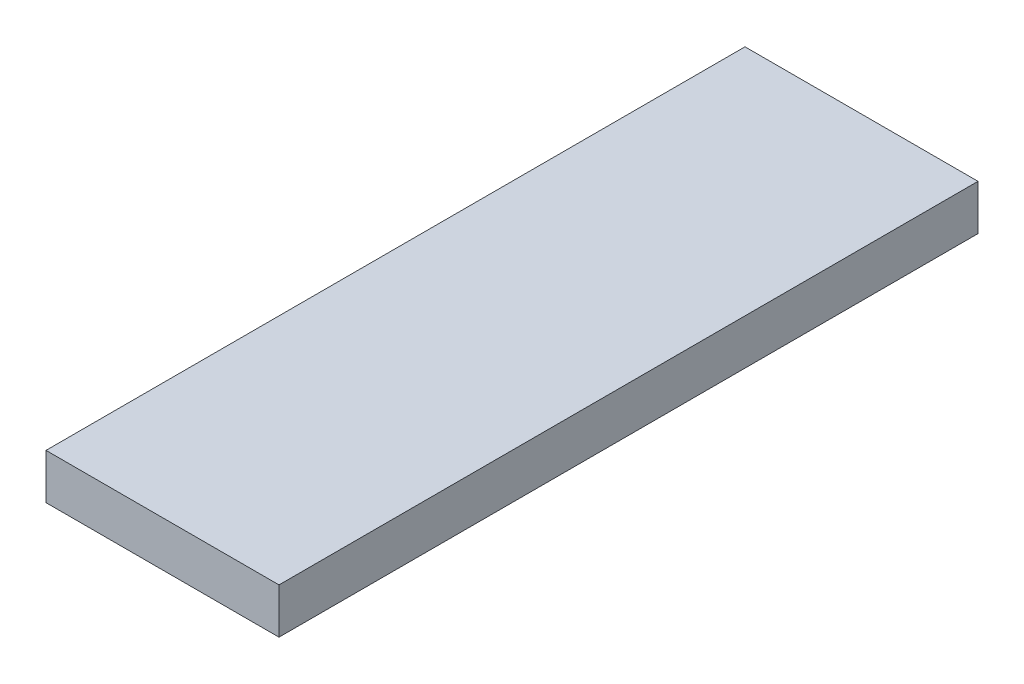
from build123d import *

# Parameters (mm, degrees)
ESBO_O1_W                = 900
ESBO_O1_H                = 175
RESSALTO_EXTRUS_O1_DEPTH = 2700


with BuildPart() as part:
    # Esboço1 → Ressalto-extrusão1 (new body)
    with BuildSketch(Plane.XY):
        with Locations((450, 87.5)):
            Rectangle(ESBO_O1_W, ESBO_O1_H)
    extrude(amount=RESSALTO_EXTRUS_O1_DEPTH)


solid = part.part
